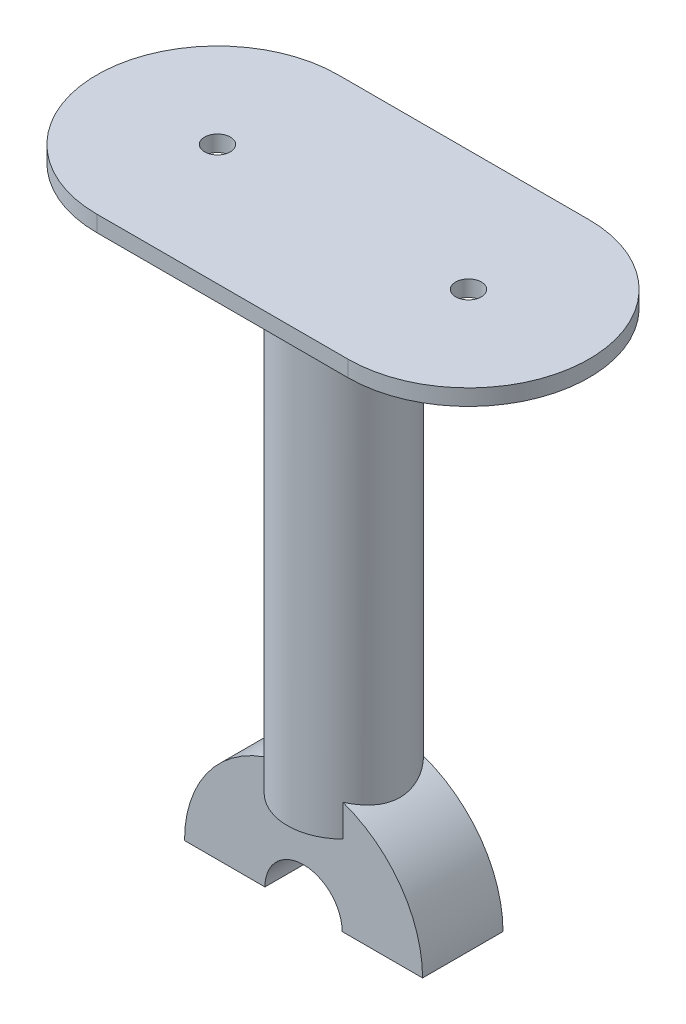
from build123d import *

# Parameters (mm, degrees)
SKETCH1_W           = 10
SKETCH1_H           = 10
REVOLVE1_ANGLE      = 180
BOSS_EXTRUDE1_START = 10
SKETCH3_R           = 7
SKETCH3_R_2         = 0.094269149
BOSS_EXTRUDE1_DEPTH = 60
SKETCH5_R           = 2.1
CUT_EXTRUDE1_DEPTH  = 6
SKETCH6_R           = 2.1
CUT_EXTRUDE2_DEPTH  = 6
BOSS_EXTRUDE3_DEPTH = 2
SKETCH14_R          = 1.6
CUT_EXTRUDE5_DEPTH  = 2


with BuildPart() as part:
    # Sketch1 → Revolve1 (revolve)
    with BuildSketch(Plane(origin=(0, 0, 0), x_dir=(1, 0, 0), z_dir=(0, 1, 0))):
        with Locations((-9.8, 5)):
            Rectangle(SKETCH1_W, SKETCH1_H)
    revolve(axis=Axis((0, 0, 3.39750235), (0, 0, -1)), revolution_arc=REVOLVE1_ANGLE)

    # Sketch3 → Boss-Extrude1 (add)
    with BuildSketch(Plane(origin=(0, 0, 0), x_dir=(1, 0, 0), z_dir=(0, 1, 0)).offset(BOSS_EXTRUDE1_START)):
        with Locations((0, 5)):
            Circle(SKETCH3_R)
        with Locations((0, 5)):
            Circle(SKETCH3_R_2, mode=Mode.SUBTRACT)
    extrude(amount=BOSS_EXTRUDE1_DEPTH)

    # Sketch5 → Cut-Extrude1 (cut)
    with BuildSketch(Plane.XZ):
        with Locations((9.8, -5)):
            Circle(SKETCH5_R)
    extrude(amount=-CUT_EXTRUDE1_DEPTH, mode=Mode.SUBTRACT)

    # Sketch6 → Cut-Extrude2 (cut)
    with BuildSketch(Plane.XZ):
        with Locations((-9.8, -5)):
            Circle(SKETCH6_R)
    extrude(amount=-CUT_EXTRUDE2_DEPTH, mode=Mode.SUBTRACT)

    # Sketch11 → Boss-Extrude3 (add)
    with BuildSketch(Plane(origin=(0, 70, 0), x_dir=(1, 0, 0), z_dir=(0, 1, 0))):
        with BuildLine():
            Line((-15.699935159, 20), (15.51139686, 20))
            ThreePointArc((15.51139686, 20), (30.51139686, 5), (15.51139686, -10))
            Line((15.51139686, -10), (-15.699935159, -10))
            ThreePointArc((-15.699935159, -10), (-30.699935159, 5), (-15.699935159, 20))
        make_face()
    extrude(amount=BOSS_EXTRUDE3_DEPTH)

    # Sketch14 → Cut-Extrude5 (cut)
    with BuildSketch(Plane(origin=(0, 72, 0), x_dir=(1, 0, 0), z_dir=(0, 1, 0))):
        with Locations((-15.699935159, 5)):
            Circle(SKETCH14_R)
        with Locations((15.51139686, 5)):
            Circle(SKETCH14_R)
    extrude(amount=-CUT_EXTRUDE5_DEPTH, mode=Mode.SUBTRACT)


solid = part.part
